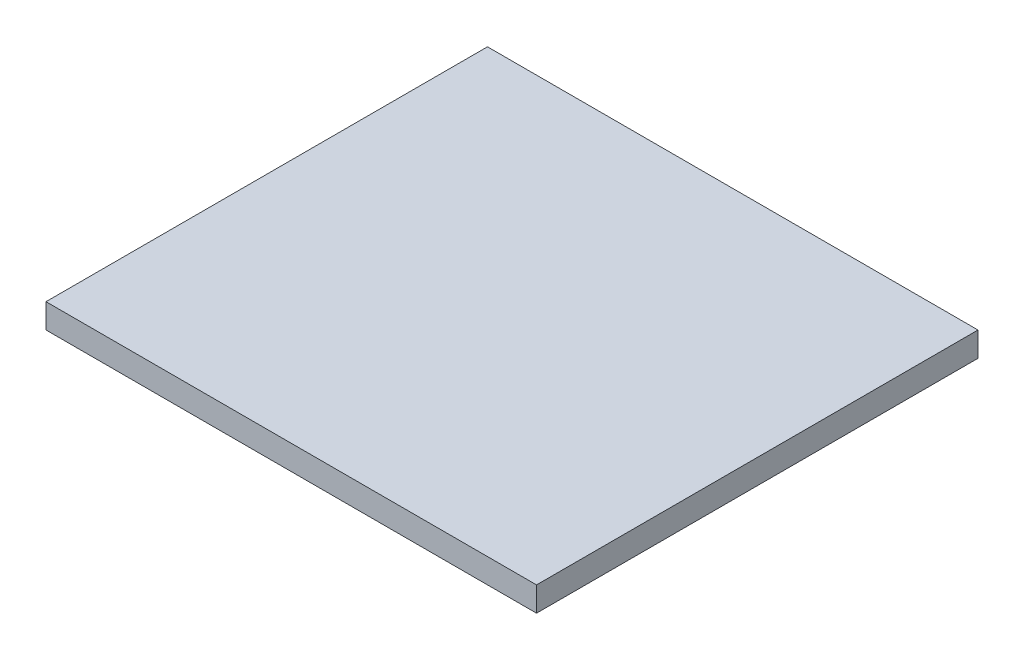
from build123d import *

# Parameters (mm, degrees)
SKETCH1_W           = 20
SKETCH1_H           = 18
BOSS_EXTRUDE1_DEPTH = 1


with BuildPart() as part:
    # Sketch1 → Boss-Extrude1 (new body)
    with BuildSketch(Plane(origin=(0, 0, 0), x_dir=(1, 0, 0), z_dir=(0, 1, 0))):
        with Locations((10, 9)):
            Rectangle(SKETCH1_W, SKETCH1_H)
    extrude(amount=BOSS_EXTRUDE1_DEPTH)


solid = part.part
